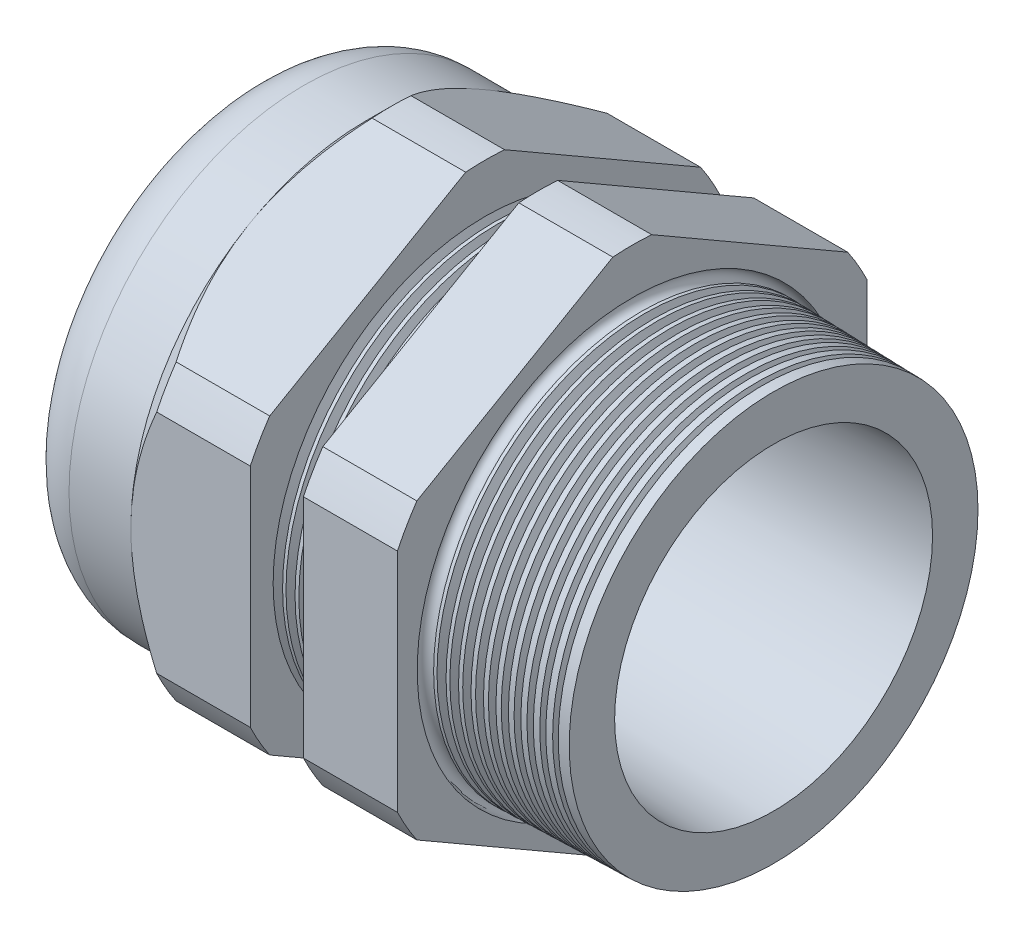
from build123d import *

# Parameters (mm, degrees)
LPATTERN6_COUNT    = 4
LPATTERN6_PITCH    = 1.5748
LPATTERN7_COUNT    = 11
LPATTERN7_PITCH    = 1.5748
SKETCH12_OUTSIDE_W = 158.354
SKETCH12_OUTSIDE_H = 158.354
CUT_EXTRUDE2_DEPTH = 53.05603
FILLET4_R          = 7.112
SKETCH19_OUTSIDE_W = 92.316
SKETCH19_OUTSIDE_H = 98.91
SKETCH19_OUTSIDE_R = 29.972
CUT_EXTRUDE3_DEPTH = 3.99796
CUT_EXTRUDE3_DRAFT = -45
SKETCH28_R         = 1.016


with BuildPart() as part:
    # Sketch10 → Revolve2 (revolve)
    with BuildSketch(Plane.XY, mode=Mode.PRIVATE) as revolve2_sk:
        Polygon((-41.89603, 19.05), (-26.65603, 19.05), (10.16, 20.28825), (10.16, 26.086938326), (-7.874, 26.559175236), (-7.874, 59.944), (-19.873976, 59.944), (-19.873976, 26.873405666), (-26.65603, 27.051), (-26.65603, 59.944), (-41.89603, 59.944), (-41.89603, 29.972), (-56.896, 29.972), (-56.896, 20.28825), (-41.89603, 20.28825), align=None)
    revolve(revolve2_sk.sketch.rotate(Axis((0, 0, 0), (-1, 0, 0)), 90), axis=Axis((0, 0, 0), (-1, 0, 0)))  # turned: the seam where the file's is

    # Sketch26 → Cut-Revolve1 (revolve, cut)
    with BuildSketch(Plane.XY, mode=Mode.PRIVATE) as cut_revolve1_sk:
        Polygon((-26.65603, 27.051), (-25.483256271, 27.020289839), (-26.096238915, 26.019993077), align=None)
    cut_revolve1 = revolve(cut_revolve1_sk.sketch.rotate(Axis((0, 0, 0), (-1, 0, 0)), 90), axis=Axis((0, 0, 0), (-1, 0, 0)), mode=Mode.SUBTRACT)  # turned: the seam where the file's is

    # LPattern6: Cut-Revolve1 ×4
    with Locations(*[(i * LPATTERN6_PITCH, 0, 0) for i in range(1, LPATTERN6_COUNT)]):
        add(cut_revolve1, mode=Mode.SUBTRACT)

    # Sketch27 → Cut-Revolve2 (revolve, cut)
    with BuildSketch(Plane.XY, mode=Mode.PRIVATE) as cut_revolve2_sk:
        Polygon((-7.874, 26.559175236), (-6.701226271, 26.528465075), (-7.314208915, 25.528168313), align=None)
    cut_revolve2 = revolve(cut_revolve2_sk.sketch.rotate(Axis((0, 0, 0), (-1, 0, 0)), 90), axis=Axis((0, 0, 0), (-1, 0, 0)), mode=Mode.SUBTRACT)  # turned: the seam where the file's is

    # LPattern7: Cut-Revolve2 ×11
    with Locations(*[(i * LPATTERN7_PITCH, 0, 0) for i in range(1, LPATTERN7_COUNT)]):
        add(cut_revolve2, mode=Mode.SUBTRACT)

    # Sketch12 outside → Cut-Extrude2 (cut, through all)
    with BuildSketch(Plane.ZY.offset(41.89603)):
        Rectangle(SKETCH12_OUTSIDE_W, SKETCH12_OUTSIDE_H)
        with BuildLine():
            Line((-2.480993384, 33.176282338), (-27.491006616, 18.736744466))
            ThreePointArc((-27.491006616, 18.736744466), (-28.811729876, 16.63446), (-29.972, 14.439537872))
            Line((-29.972, 14.439537872), (-29.972, -14.439537872))
            ThreePointArc((-29.972, -14.439537872), (-28.811729876, -16.63446), (-27.491006616, -18.736744466))
            Line((-27.491006616, -18.736744466), (-2.480993384, -33.176282338))
            ThreePointArc((-2.480993384, -33.176282338), (0, -33.26892), (2.480993384, -33.176282338))
            Line((2.480993384, -33.176282338), (27.491006616, -18.736744466))
            ThreePointArc((27.491006616, -18.736744466), (28.811729876, -16.63446), (29.972, -14.439537872))
            Line((29.972, -14.439537872), (29.972, 14.439537872))
            ThreePointArc((29.972, 14.439537872), (28.811729876, 16.63446), (27.491006616, 18.736744466))
            Line((27.491006616, 18.736744466), (2.480993384, 33.176282338))
            ThreePointArc((2.480993384, 33.176282338), (0, 33.26892), (-2.480993384, 33.176282338))
        make_face(mode=Mode.SUBTRACT)
    extrude(amount=-CUT_EXTRUDE2_DEPTH, mode=Mode.SUBTRACT)

    # Fillet4
    fillet4_edges = [part.edges().sort_by_distance(p)[0] for p in [
        (-56.896, 0, 29.972),
    ]]
    fillet(fillet4_edges, radius=FILLET4_R)


with BuildPart() as body_2:
    # Sketch23 → Revolve6 (revolve)
    with BuildSketch(Plane.XY, mode=Mode.PRIVATE) as revolve6_sk:
        with BuildLine():
            Line((-55.9054, 20.28825), (-41.89603, 20.28825))
            Line((-41.89603, 20.28825), (-41.89603, 19.05))
            Line((-41.89603, 19.05), (-56.134, 19.05))
            Line((-56.134, 19.05), (-56.134, 20.05965))
            ThreePointArc((-56.134, 20.05965), (-56.06704461, 20.22129461), (-55.9054, 20.28825))
        make_face()
    revolve(revolve6_sk.sketch.rotate(Axis((0, 0, 0), (-1, 0, 0)), 90), axis=Axis((0, 0, 0), (-1, 0, 0)))  # turned: the seam where the file's is


with BuildPart() as cut_extrude3_tool:
    # Sketch19 outside → Cut-Extrude3 (with draft: the straight prism first)
    with BuildSketch(Plane.ZY.offset(41.89603)):
        Rectangle(SKETCH19_OUTSIDE_W, SKETCH19_OUTSIDE_H)
        Circle(SKETCH19_OUTSIDE_R, mode=Mode.SUBTRACT)
    extrude(amount=-CUT_EXTRUDE3_DEPTH)
    # Cut-Extrude3: the draft: its side faces are tilted about the plane it starts from
    cut_extrude3_sides = [cut_extrude3_tool.faces().sort_by_distance(p)[0] for p in [
        (-39.89705, -49.455, 0),
        (-39.89705, 0, 46.158),
        (-39.89705, 49.455, 0),
        (-39.89705, 0, -46.158),
        (-39.89705, 0, -29.972),
    ]]
    draft(cut_extrude3_sides, Plane.ZY.offset(41.89603), CUT_EXTRUDE3_DRAFT)


with BuildPart() as part_1:
    add(part.part)

    # Cut-Extrude3: cut by cut_extrude3_tool
    add(cut_extrude3_tool.part, mode=Mode.SUBTRACT)

    # Sketch28 → Cut-Revolve3 (revolve, cut)
    with BuildSketch(Plane.XY, mode=Mode.PRIVATE) as cut_revolve3_sk:
        with Locations((-7.8486, -26.432175236)):
            Circle(SKETCH28_R)
    revolve(cut_revolve3_sk.sketch.rotate(Axis((10.16, 0, 0), (-1, 0, 0)), 90), axis=Axis((10.16, 0, 0), (-1, 0, 0)), mode=Mode.SUBTRACT)  # turned: the seam where the file's is


solid = Compound([body_2.part, part_1.part])
